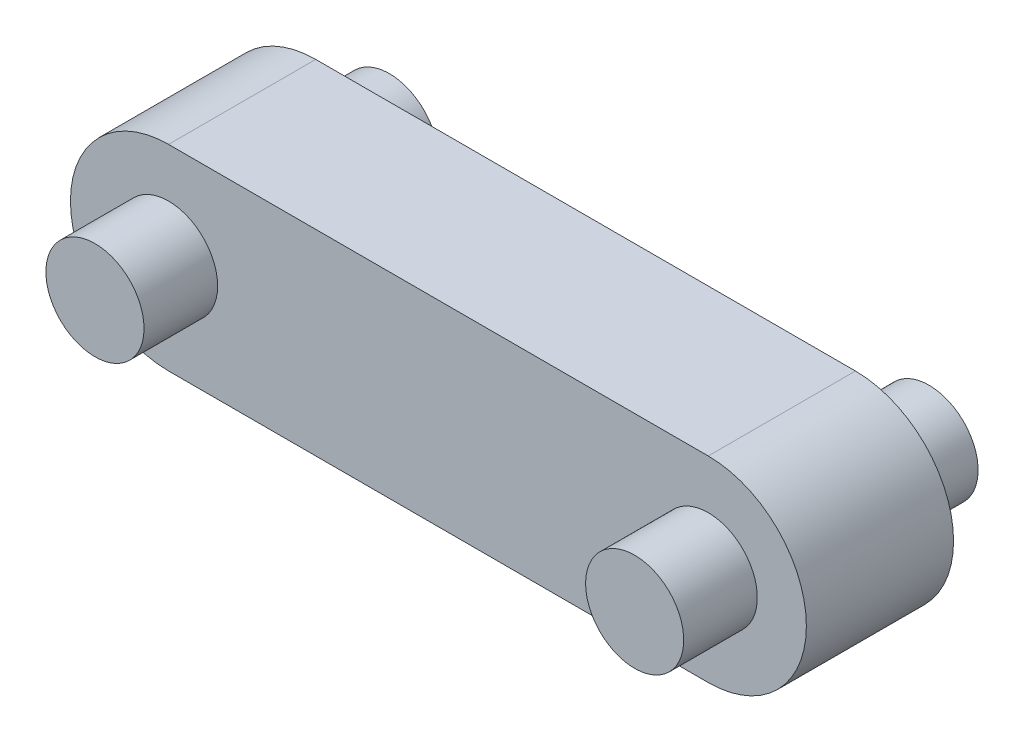
from build123d import *

# Parameters (mm, degrees)
SKETCH1_R           = 10
BOSS_EXTRUDE1_DEPTH = 30
BOSS_EXTRUDE2_DEPTH = 15


with BuildPart() as part:
    # Sketch1 → Boss-Extrude1 (new body, symmetric)
    with BuildSketch(Plane.XY):
        Circle(SKETCH1_R)
    boss_extrude1 = extrude(amount=BOSS_EXTRUDE1_DEPTH, both=True)

    # Sketch2 → Boss-Extrude2 (add, symmetric)
    with BuildSketch(Plane.XY):
        with BuildLine():
            Line((0, 20), (55, 20))
            Line((55, 20), (55, -20))
            Line((55, -20), (0, -20))
            ThreePointArc((0, -20), (-20, 0), (0, 20))
        make_face()
    boss_extrude2 = extrude(amount=BOSS_EXTRUDE2_DEPTH, both=True)

    # Mirror1: Boss-Extrude1, Boss-Extrude2 across plane
    add(boss_extrude1.mirror(Plane(origin=(55, 20, 15), x_dir=(0, 0, 1), z_dir=(-1, 0, 0))))
    add(boss_extrude2.mirror(Plane(origin=(55, 20, 15), x_dir=(0, 0, 1), z_dir=(-1, 0, 0))))


solid = part.part
